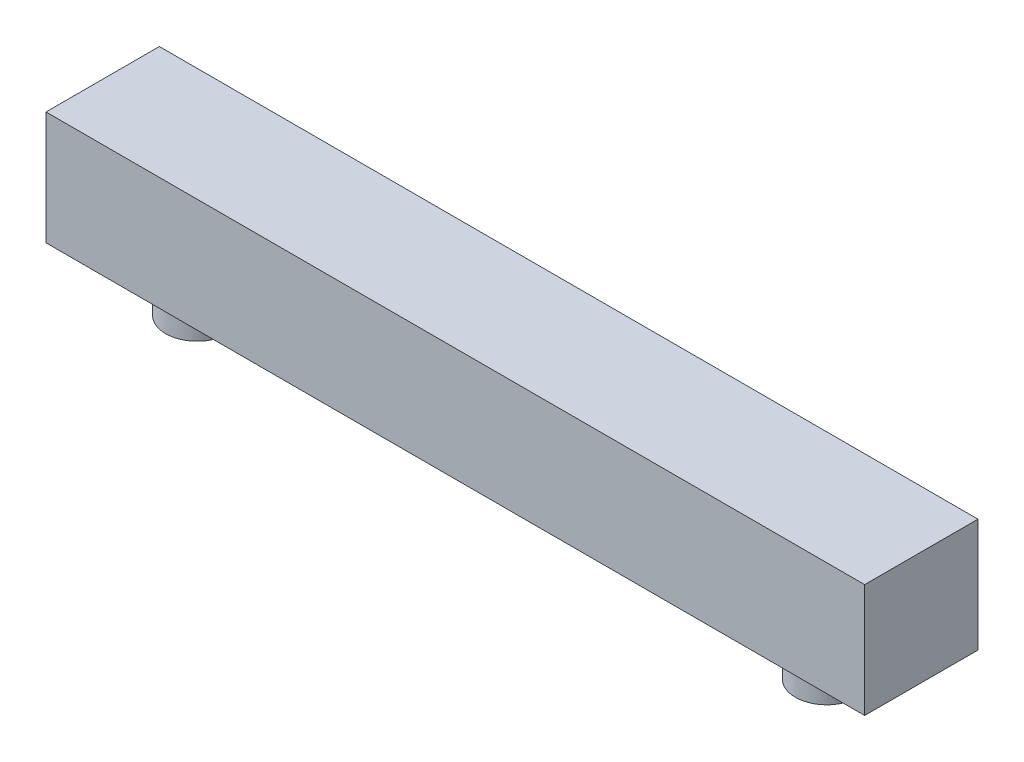
from build123d import *

# Parameters (mm, degrees)
SKETCH1_W           = 65
SKETCH1_H           = 9
BOSS_EXTRUDE1_DEPTH = 9
SKETCH2_R           = 2.5
BOSS_EXTRUDE2_DEPTH = 3.5


with BuildPart() as part:
    # Sketch1 → Boss-Extrude1 (new body)
    with BuildSketch(Plane(origin=(0, 0, 0), x_dir=(1, 0, 0), z_dir=(0, 1, 0))):
        with Locations((32.5, -4.5)):
            Rectangle(SKETCH1_W, SKETCH1_H)
    extrude(amount=BOSS_EXTRUDE1_DEPTH)

    # Sketch2 → Boss-Extrude2 (add)
    with BuildSketch(Plane.XZ):
        with Locations(Location((7.5, 4.5, 0), (0, 0, 90))):  # turned: the seam where the file's is
            Circle(SKETCH2_R)
        with Locations(Location((57.5, 4.5, 0), (0, 0, 90))):  # turned: the seam where the file's is
            Circle(SKETCH2_R)
    extrude(amount=BOSS_EXTRUDE2_DEPTH)


solid = part.part
